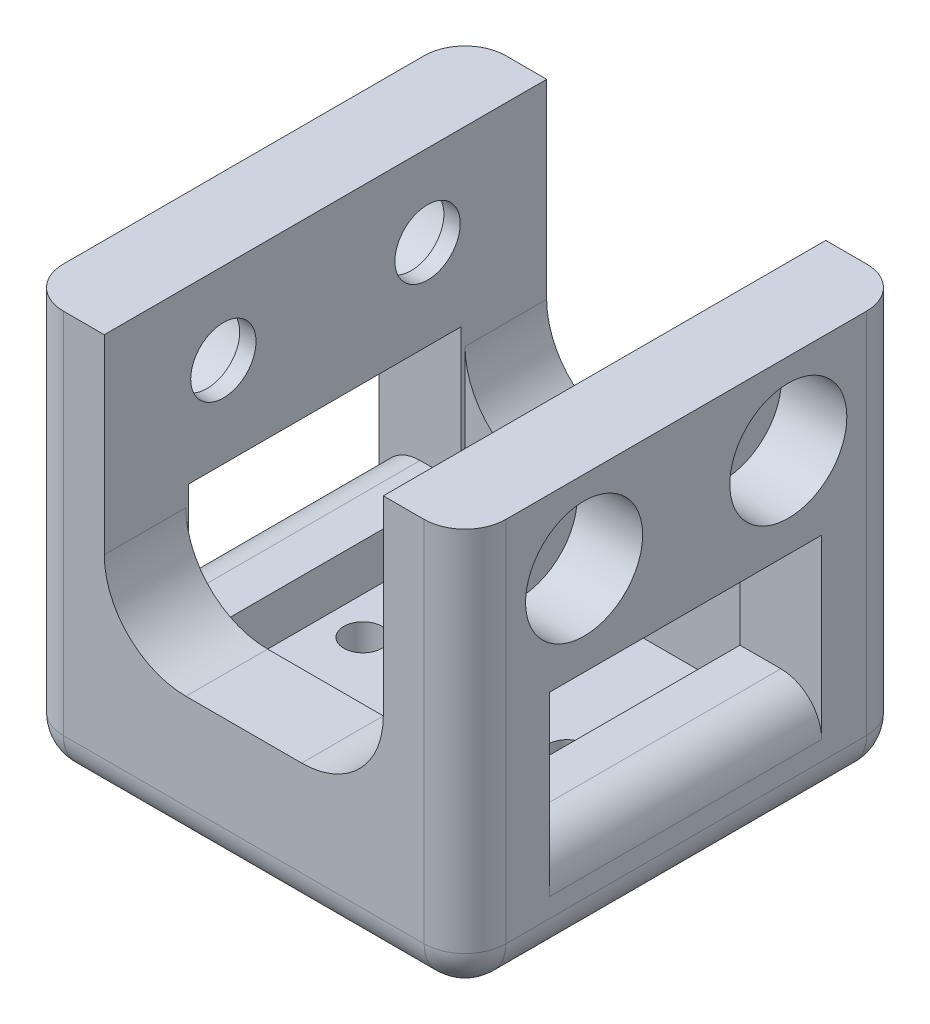
from build123d import *

# Parameters (mm, degrees)
SKETCH1_W           = 26.035
SKETCH1_H           = 26.035
SKETCH1_R           = 1.778
BOSS_EXTRUDE1_DEPTH = 5.08
SKETCH9_W           = 41.275
SKETCH9_H           = 41.275
SKETCH9_W_2         = 26.035
SKETCH9_H_2         = 26.035
BOSS_EXTRUDE7_DEPTH = 38.1
CUT_EXTRUDE4_DEPTH  = 42.275
SKETCH11_R          = 3.048
CUT_EXTRUDE5_DEPTH  = 42.275
FILLET1_R           = 3.81
FILLET2_R           = 3.81
SKETCH12_R          = 5.461
SKETCH12_R_2        = 3.048
CUT_EXTRUDE6_DEPTH  = 6.096
CUT_EXTRUDE7_START  = -41.275
SKETCH12_3_R        = 5.461
CUT_EXTRUDE7_DEPTH  = 6.096
SKETCH13_W          = 25.4
SKETCH13_H          = 12.7
CUT_EXTRUDE8_DEPTH  = 42.275
FILLET3_R           = 3.81
FILLET4_R           = 3.81


with BuildPart() as part:
    # Sketch1 → Boss-Extrude1 (new body)
    with BuildSketch(Plane(origin=(0, 0, 0), x_dir=(1, 0, 0), z_dir=(0, 1, 0))):
        Rectangle(SKETCH1_W, SKETCH1_H)
        with Locations((0, 9.525)):
            Circle(SKETCH1_R, mode=Mode.SUBTRACT)
        with Locations((-9.525, 0)):
            Circle(SKETCH1_R, mode=Mode.SUBTRACT)
        with Locations((9.525, 0)):
            Circle(SKETCH1_R, mode=Mode.SUBTRACT)
        with Locations((0, -9.525)):
            Circle(SKETCH1_R, mode=Mode.SUBTRACT)
    extrude(amount=BOSS_EXTRUDE1_DEPTH)

    # Sketch9 → Boss-Extrude7 (add)
    with BuildSketch(Plane.XZ):
        Rectangle(SKETCH9_W, SKETCH9_H)
        Rectangle(SKETCH9_W_2, SKETCH9_H_2, mode=Mode.SUBTRACT)
    extrude(amount=-BOSS_EXTRUDE7_DEPTH)

    # Sketch10 → Cut-Extrude4 (cut, through all)
    with BuildSketch(Plane.XY.offset(20.6375)):
        with BuildLine():
            Line((-13.0175, 20.32), (-13.0175, 38.1))
            Line((-13.0175, 38.1), (13.0175, 38.1))
            Line((13.0175, 38.1), (13.0175, 20.32))
            ThreePointArc((13.0175, 20.32), (10.785653673, 14.931846327), (5.3975, 12.7))
            Line((5.3975, 12.7), (-5.3975, 12.7))
            ThreePointArc((-5.3975, 12.7), (-10.785653673, 14.931846327), (-13.0175, 20.32))
        make_face()
    extrude(amount=-CUT_EXTRUDE4_DEPTH, mode=Mode.SUBTRACT)

    # Sketch11 → Cut-Extrude5 (cut, through all)
    with BuildSketch(Plane.ZY.offset(20.6375)):
        with Locations((-9.525, 30.48)):
            Circle(SKETCH11_R)
        with Locations((9.525, 30.48)):
            Circle(SKETCH11_R)
    extrude(amount=-CUT_EXTRUDE5_DEPTH, mode=Mode.SUBTRACT)

    # Fillet1
    fillet1_edges = [part.edges().sort_by_distance(p)[0] for p in [
        (20.6375, 19.05, -20.6375),
        (-20.6375, 19.05, -20.6375),
        (-20.6375, 19.05, 20.6375),
        (20.6375, 19.05, 20.6375),
    ]]
    fillet(fillet1_edges, radius=FILLET1_R)

    # Fillet2
    fillet2_edges = [part.edges().sort_by_distance(p)[0] for p in [
        (0, 0, -20.6375),
        (20.6375, 0, 0),
        (0, 0, 20.6375),
        (-20.6375, 0, 0),
        (-19.521576836, 0, 19.521576836),
        (-19.521576836, 0, -19.521576836),
        (19.521576836, 0, 19.521576836),
        (19.521576836, 0, -19.521576836),
    ]]
    fillet(fillet2_edges, radius=FILLET2_R)

    # Sketch12 → Cut-Extrude6 (cut)
    with BuildSketch(Plane.ZY.offset(20.6375)):
        with Locations((-9.525, 30.48)):
            Circle(SKETCH12_R)
        with Locations((-9.525, 30.48)):
            Circle(SKETCH12_R_2, mode=Mode.SUBTRACT)
        with Locations((9.525, 30.48)):
            Circle(SKETCH12_R)
        with Locations((9.525, 30.48)):
            Circle(SKETCH12_R_2, mode=Mode.SUBTRACT)
    extrude(amount=-CUT_EXTRUDE6_DEPTH, mode=Mode.SUBTRACT)

    # Sketch12_3 → Cut-Extrude7 (cut)
    with BuildSketch(Plane.ZY.offset(20.6375).offset(CUT_EXTRUDE7_START)):
        with Locations((-9.525, 30.48)):
            Circle(SKETCH12_3_R)
        with Locations((9.525, 30.48)):
            Circle(SKETCH12_3_R)
    extrude(amount=CUT_EXTRUDE7_DEPTH, mode=Mode.SUBTRACT)

    # Sketch13 → Cut-Extrude8 (cut, through all)
    with BuildSketch(Plane.ZY.offset(20.6375)):
        with Locations((0.0635, 15.748)):
            Rectangle(SKETCH13_W, SKETCH13_H)
    extrude(amount=-CUT_EXTRUDE8_DEPTH, mode=Mode.SUBTRACT)

    # Fillet3
    fillet3_edges = [part.edges().sort_by_distance(p)[0] for p in [
        (-20.6375, 9.398, 0.0635),
    ]]
    fillet(fillet3_edges, radius=FILLET3_R)

    # Fillet4
    fillet4_edges = [part.edges().sort_by_distance(p)[0] for p in [
        (20.6375, 9.398, 0.0635),
    ]]
    fillet(fillet4_edges, radius=FILLET4_R)


solid = part.part
